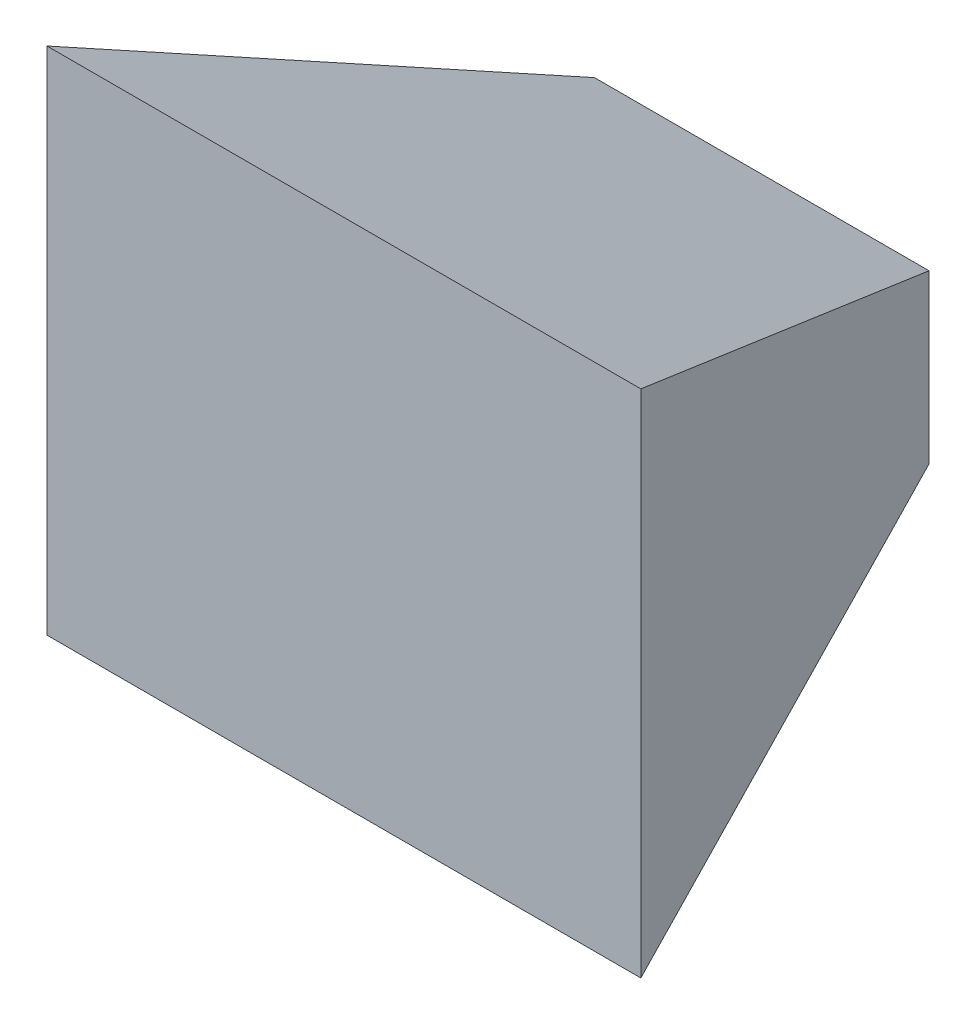
from build123d import *

# Parameters (mm, degrees)
BOSS_EXTRUDE2_DEPTH = 177.5
CUT_EXTRUDE1_DEPTH  = 152.5


with BuildPart() as part:
    # Sketch2 → Boss-Extrude2 (new body, symmetric)
    with BuildSketch(Plane(origin=(0, 0, 0), x_dir=(0, 0, -1), z_dir=(1, 0, 0))):
        Polygon((0, 152.5), (0, -152.5), (249.787409611, -50), (249.787409611, 50), align=None)
    extrude(amount=BOSS_EXTRUDE2_DEPTH, both=True)

    # Sketch3 → Cut-Extrude1 (cut, symmetric)
    with BuildSketch(Plane(origin=(0, 0, 0), x_dir=(1, 0, 0), z_dir=(0, 1, 0))):
        Polygon((-177.5, 249.787409611), (-100, 249.787409611), (-177.5, 0), align=None)
        Polygon((177.5, 0), (177.5, 249.787409611), (100, 249.787409611), align=None)
    extrude(amount=CUT_EXTRUDE1_DEPTH, both=True, mode=Mode.SUBTRACT)


solid = part.part
